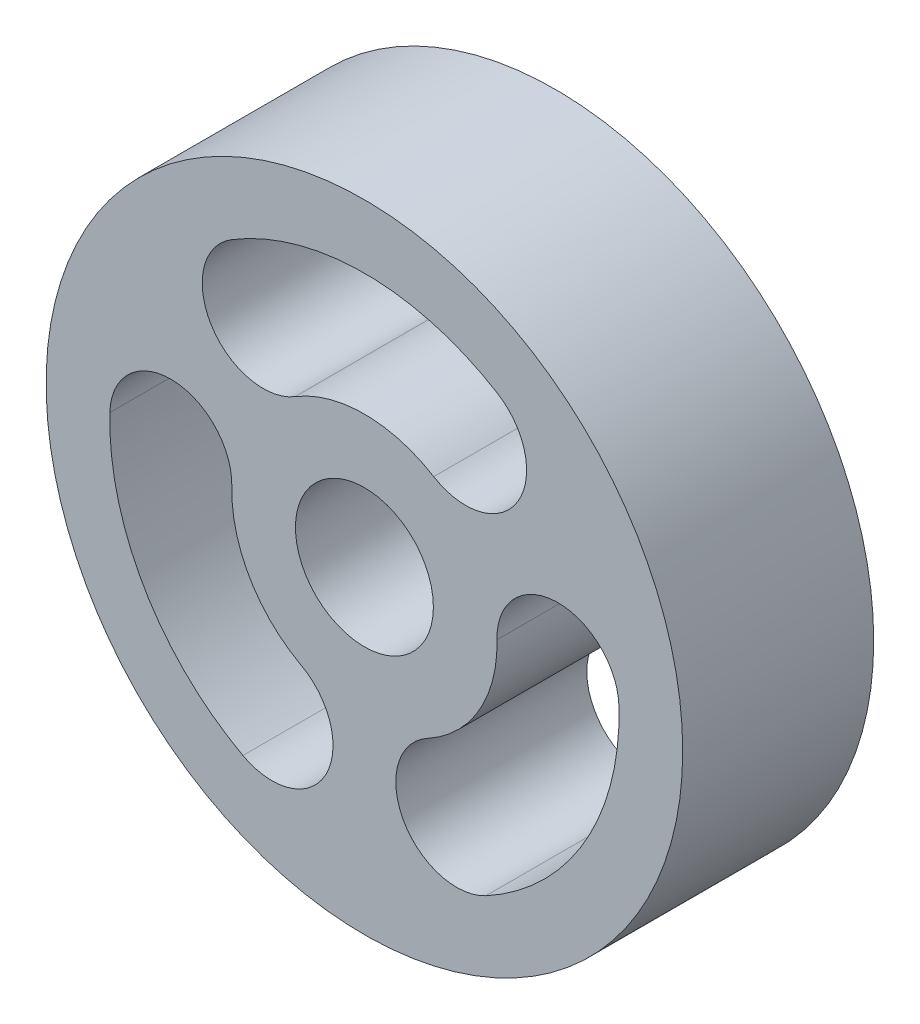
from build123d import *

# Parameters (mm, degrees)
SKETCH_1_R      = 15
SKETCH_1_R_2    = 3.25
EXTRUDE_1_DEPTH = 9


with BuildPart() as part:
    # 草图1 → 凸台-拉伸1 (new body)
    with BuildSketch(Plane.XY):
        Circle(SKETCH_1_R)
        Circle(SKETCH_1_R_2, mode=Mode.SUBTRACT)
        with BuildLine():
            ThreePointArc((6.269982777, 10.231681972), (0, 12), (-6.269982777, 10.231681972))
            ThreePointArc((-6.269982777, 10.231681972), (-7.219139876, 6.278158126), (-3.265616029, 5.329001027))
            ThreePointArc((-3.265616029, 5.329001027), (0, 6.25), (3.265616029, 5.329001027))
            ThreePointArc((3.265616029, 5.329001027), (7.219139876, 6.278158126), (6.269982777, 10.231681972))
        make_face(mode=Mode.SUBTRACT)
        with BuildLine():
            ThreePointArc((5.725905123, -10.545805352), (10.392304845, -6), (11.9958879, 0.31412338))
            ThreePointArc((11.9958879, 0.31412338), (9.046614364, 3.112879463), (6.247858281, 0.163605927))
            ThreePointArc((6.247858281, 0.163605927), (5.412658774, -3.125), (2.982242252, -5.492606954))
            ThreePointArc((2.982242252, -5.492606954), (1.827474488, -9.391037589), (5.725905123, -10.545805352))
        make_face(mode=Mode.SUBTRACT)
        with BuildLine():
            ThreePointArc((-11.9958879, 0.31412338), (-10.392304845, -6), (-5.725905123, -10.545805352))
            ThreePointArc((-5.725905123, -10.545805352), (-1.827474488, -9.391037589), (-2.982242252, -5.492606954))
            ThreePointArc((-2.982242252, -5.492606954), (-5.412658774, -3.125), (-6.247858281, 0.163605927))
            ThreePointArc((-6.247858281, 0.163605927), (-9.046614364, 3.112879463), (-11.9958879, 0.31412338))
        make_face(mode=Mode.SUBTRACT)
    extrude(amount=EXTRUDE_1_DEPTH)


solid = part.part
